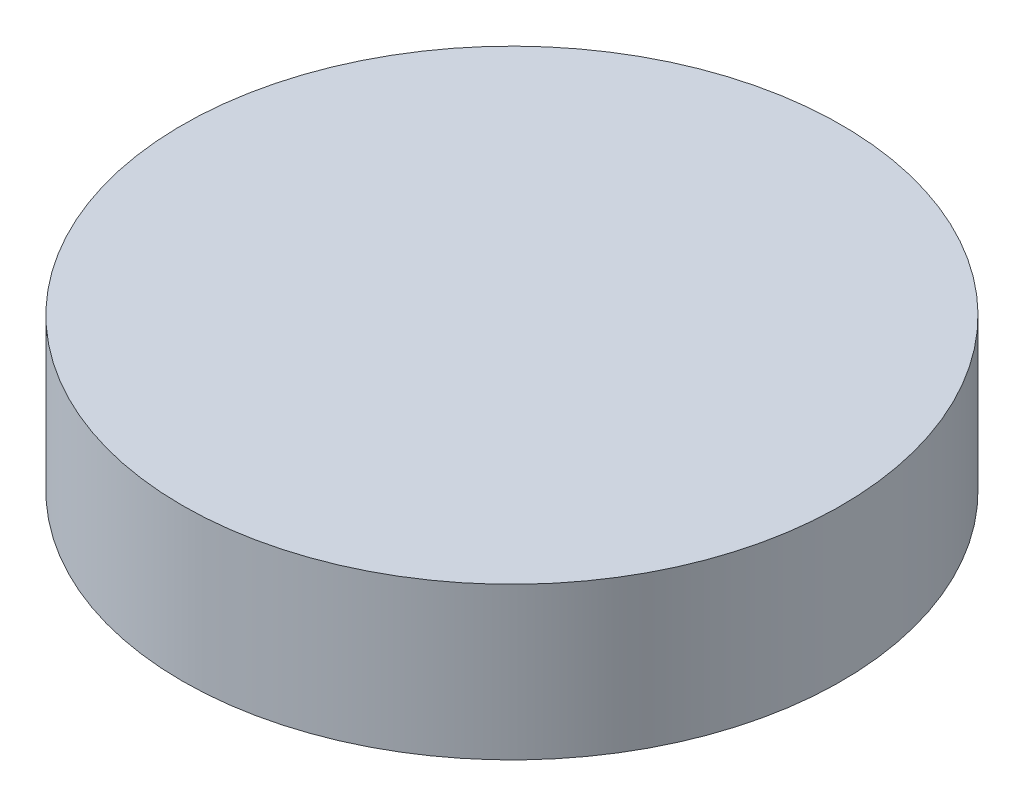
from build123d import *

# Parameters (mm, degrees)
SKETCH1_R           = 65
BOSS_EXTRUDE1_DEPTH = 30


with BuildPart() as part:
    # Sketch1 → Boss-Extrude1 (new body)
    with BuildSketch(Plane(origin=(0, 0, 0), x_dir=(1, 0, 0), z_dir=(0, 1, 0))):
        Circle(SKETCH1_R)
    extrude(amount=BOSS_EXTRUDE1_DEPTH)


solid = part.part
